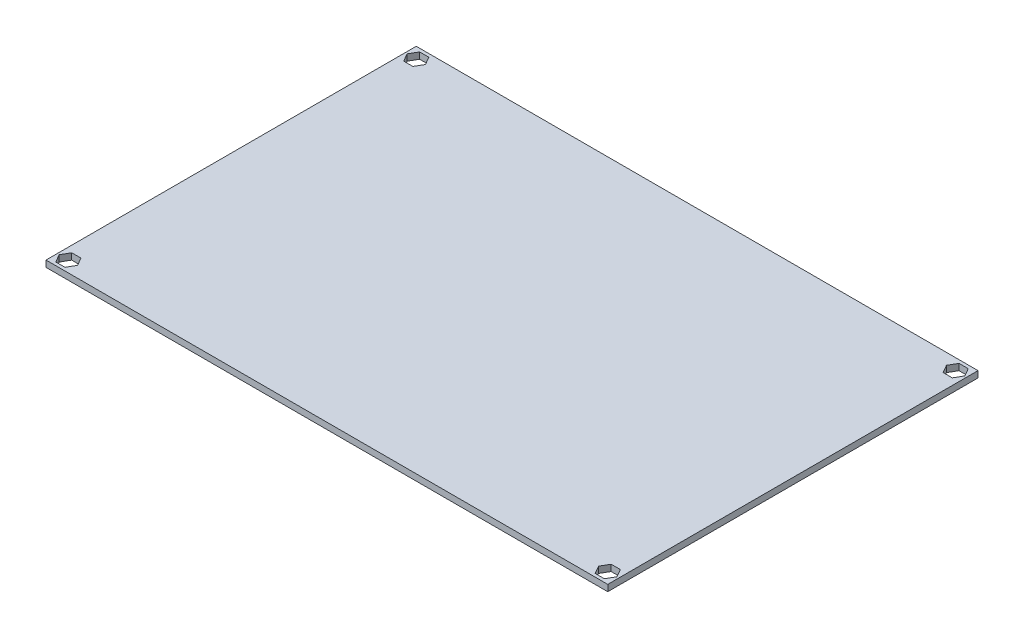
from build123d import *

# Parameters (mm, degrees)
SKETCH1_W           = 176
SKETCH1_H           = 116
BOSS_EXTRUDE1_DEPTH = 2
CUT_EXTRUDE2_DEPTH  = 2


with BuildPart() as part:
    # Sketch1 → Boss-Extrude1 (new body)
    with BuildSketch(Plane(origin=(0, 0, 0), x_dir=(1, 0, 0), z_dir=(0, 1, 0))):
        with Locations((7.780713342, 12.143989432)):
            Rectangle(SKETCH1_W, SKETCH1_H)
    extrude(amount=BOSS_EXTRUDE1_DEPTH)

    # Sketch3 → Cut-Extrude2 (cut)
    with BuildSketch(Plane(origin=(0, 2, 0), x_dir=(1, 0, 0), z_dir=(0, 1, 0))):
        Polygon((-75.275910985, 64.143989432), (-73.832535312, 66.643989432), (-75.275910985, 69.143989432), (-78.162662331, 69.143989432), (-79.606038004, 66.643989432), (-78.162662331, 64.143989432), align=None)
        Polygon((93.724089015, 64.143989432), (90.837337669, 64.143989432), (89.393961996, 66.643989432), (90.837337669, 69.143989432), (93.724089015, 69.143989432), (95.167464688, 66.643989432), align=None)
        Polygon((90.837337669, -39.856010568), (89.393961996, -42.356010568), (90.837337669, -44.856010568), (93.724089015, -44.856010568), (95.167464688, -42.356010568), (93.724089015, -39.856010568), align=None)
        Polygon((-78.162662331, -39.856010568), (-75.275910985, -39.856010568), (-73.832535312, -42.356010568), (-75.275910985, -44.856010568), (-78.162662331, -44.856010568), (-79.606038004, -42.356010568), align=None)
    extrude(amount=-CUT_EXTRUDE2_DEPTH, mode=Mode.SUBTRACT)


solid = part.part
